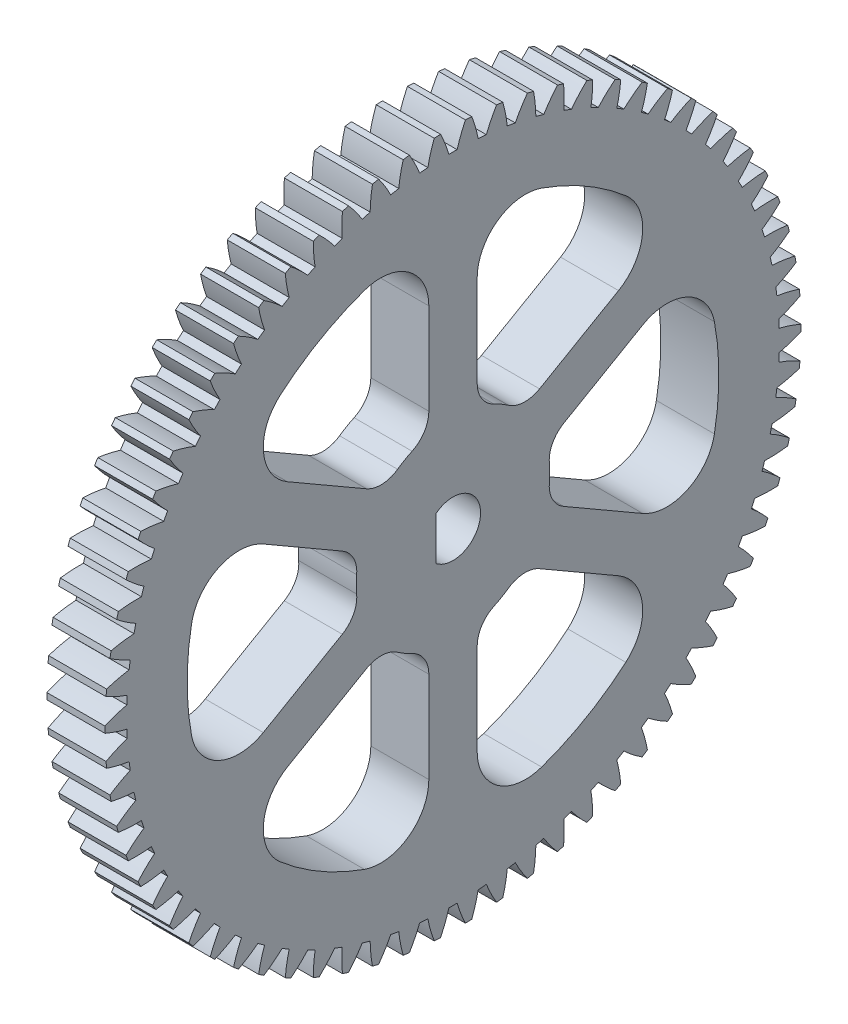
from build123d import *

# Parameters (mm, degrees)
BASPROSKE_W              = 6
BASPROSKE_H              = 36
TOOTHCUT_DEPTH           = 52.264022472
TEETHCUTS_COUNT          = 70
TEETHCUTS_ANGLE          = 354.857142857
CUT_EXTRUDE1_DEPTH       = 52.2478262
CUT_EXTRUDE2_DEPTH       = 52.2478262
FILLET1_R                = 5
FILLET2_R                = 3
CIRPATTERN1_COUNT        = 6
FILLET1_OF_CIRPATTERN1_R = 5
FILLET2_OF_CIRPATTERN1_R = 3


with BuildPart() as part:
    # BasProSke → Base-Revolve (revolve)
    with BuildSketch(Plane(origin=(0, 0, 0), x_dir=(1, 0, 0), z_dir=(0, 1, 0)), mode=Mode.PRIVATE) as base_revolve_sk:
        with Locations((3, 18)):
            Rectangle(BASPROSKE_W, BASPROSKE_H)
    revolve(base_revolve_sk.sketch.rotate(Axis((-10, 0, 0), (1, 0, 0)), 180), axis=Axis((-10, 0, 0), (1, 0, 0)))

    # TooCutSke → ToothCut (cut, through all)
    with BuildSketch(Plane(origin=(0, 0, 0), x_dir=(0, 0, -1), z_dir=(1, 0, 0))):
        with BuildLine():
            ThreePointArc((0.424697366, 33.746327699), (0, 33.749), (-0.424697366, 33.746327699))
            ThreePointArc((-0.424697366, 33.746327699), (-0.813915982, 34.893081227), (-1.300780296, 36.001908502))
            ThreePointArc((-1.300780296, 36.001908502), (0, 36.0254), (1.300780296, 36.001908502))
            ThreePointArc((1.300780296, 36.001908502), (0.813915982, 34.893081227), (0.424697366, 33.746327699))
        make_face()
    toothcut = extrude(amount=TOOTHCUT_DEPTH, mode=Mode.SUBTRACT)

    # TeethCuts: ToothCut ×70 about axis
    teethcuts_axis = Axis((-10, 0, 0), (1, 0, 0))
    for i in range(1, TEETHCUTS_COUNT):
        add(toothcut.rotate(teethcuts_axis, i * TEETHCUTS_ANGLE / (TEETHCUTS_COUNT - 1)), mode=Mode.SUBTRACT)

    # Sketch1 → Cut-Extrude1 (cut, through all)
    with BuildSketch(Plane(origin=(6, 0, 0), x_dir=(0, 0, -1), z_dir=(1, 0, 0))):
        with BuildLine():
            Line((-1.749285568, 2.25), (-1.749285568, -2.25))
            ThreePointArc((-1.749285568, -2.25), (2.85, 0), (-1.749285568, 2.25))
        make_face()
    extrude(amount=-CUT_EXTRUDE1_DEPTH, mode=Mode.SUBTRACT)

    # Sketch2 → Cut-Extrude2 (cut, through all)
    with BuildSketch(Plane(origin=(6, 0, 0), x_dir=(0, 0, -1), z_dir=(1, 0, 0))):
        with BuildLine():
            Line((-2.5, 27.386127875), (-2.5, 9.682458366))
            ThreePointArc((-2.5, 9.682458366), (-5, 8.660254038), (-7.135254916, 7.006292692))
            Line((-7.135254916, 7.006292692), (-22.467082451, 15.858127447))
            ThreePointArc((-22.467082451, 15.858127447), (-13.75, 23.815698604), (-2.5, 27.386127875))
        make_face()
    cut_extrude2 = extrude(amount=-CUT_EXTRUDE2_DEPTH, mode=Mode.SUBTRACT)

    # Fillet1
    fillet1_edges = [part.edges().sort_by_distance(p)[0] for p in [
        (3, 15.858127447, 22.467082451),
        (3, 27.386127875, 2.5),
    ]]
    fillet(fillet1_edges, radius=FILLET1_R)

    # Fillet2
    fillet2_edges = [part.edges().sort_by_distance(p)[0] for p in [
        (3, 9.682458366, 2.5),
        (3, 7.006292692, 7.135254916),
    ]]
    fillet(fillet2_edges, radius=FILLET2_R)

    # CirPattern1: Cut-Extrude2 ×6 about axis
    cirpattern1_axis = Axis((0, 0, 0), (1, 0, 0))
    for i in range(1, CIRPATTERN1_COUNT):
        add(cut_extrude2.rotate(cirpattern1_axis, i * 360 / CIRPATTERN1_COUNT), mode=Mode.SUBTRACT)

    # Fillet1 of CirPattern1
    fillet1_of_cirpattern1_edges = [part.edges().sort_by_distance(p)[0] for p in [
        (3, -11.528000428, 24.967082451),
        (3, 11.528000428, 24.967082451),
        (3, -27.386127875, 2.5),
        (3, -15.858127447, 22.467082451),
        (3, -15.858127447, -22.467082451),
        (3, -27.386127875, -2.5),
        (3, 11.528000428, -24.967082451),
        (3, -11.528000428, -24.967082451),
        (3, 27.386127875, -2.5),
        (3, 15.858127447, -22.467082451),
    ]]
    fillet(fillet1_of_cirpattern1_edges, radius=FILLET1_OF_CIRPATTERN1_R)

    # Fillet2 of CirPattern1
    fillet2_of_cirpattern1_edges = [part.edges().sort_by_distance(p)[0] for p in [
        (3, 2.676165673, 9.635254916),
        (3, -2.676165673, 9.635254916),
        (3, -7.006292692, 7.135254916),
        (3, -9.682458366, 2.5),
        (3, -9.682458366, -2.5),
        (3, -7.006292692, -7.135254916),
        (3, -2.676165673, -9.635254916),
        (3, 2.676165673, -9.635254916),
        (3, 7.006292692, -7.135254916),
        (3, 9.682458366, -2.5),
    ]]
    fillet(fillet2_of_cirpattern1_edges, radius=FILLET2_OF_CIRPATTERN1_R)


solid = part.part
